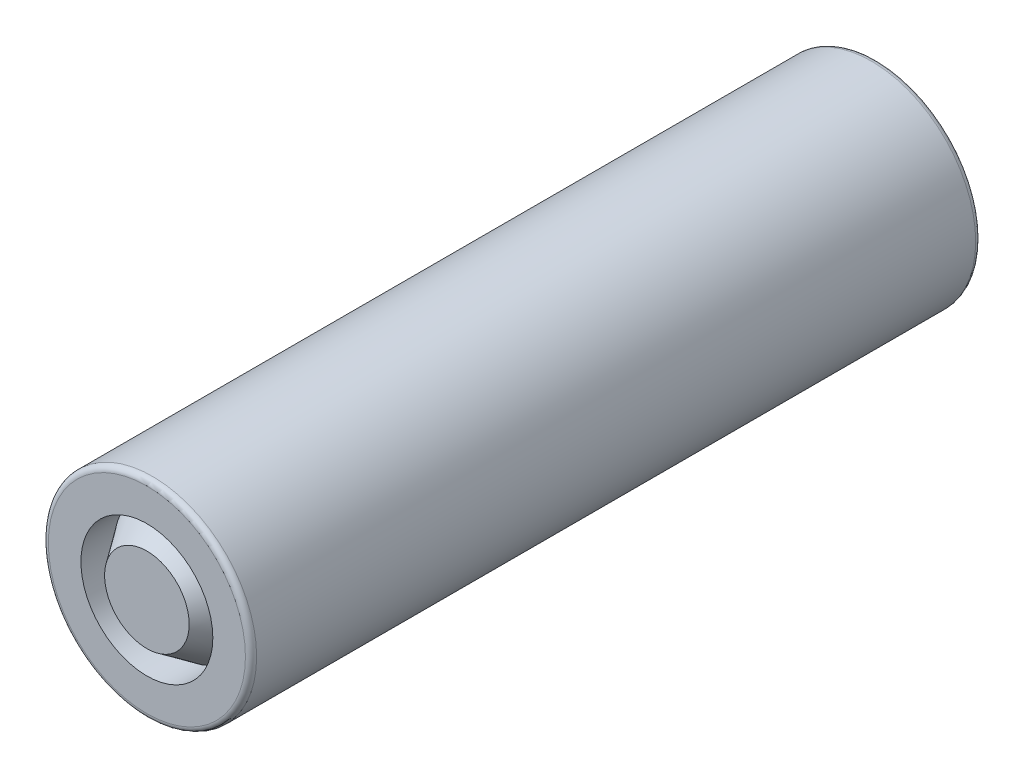
from build123d import *

# Parameters (mm, degrees)
SKETCH1_R           = 9.3
BOSS_EXTRUDE1_DEPTH = 65.2
FILLET1_R           = 0.5


with BuildPart() as part:
    # Sketch1 → Boss-Extrude1 (new body)
    with BuildSketch(Plane.XY):
        Circle(SKETCH1_R)
    extrude(amount=-BOSS_EXTRUDE1_DEPTH)

    # Sketch3 → Cut-Revolve1 (revolve, cut)
    with BuildSketch(Plane(origin=(0, 0, 0), x_dir=(0, 0, -1), z_dir=(1, 0, 0))):
        Polygon((0, 5.89), (0, 3.775), (3, 5.89), align=None)
    revolve(axis=Axis((0, 0, 55), (0, 0, -1)), mode=Mode.SUBTRACT)

    # Fillet1
    fillet1_edges = [part.edges().sort_by_distance(p)[0] for p in [
        (-9.3, 0, 0),
        (-9.3, 0, -65.2),
    ]]
    fillet(fillet1_edges, radius=FILLET1_R)


solid = part.part
